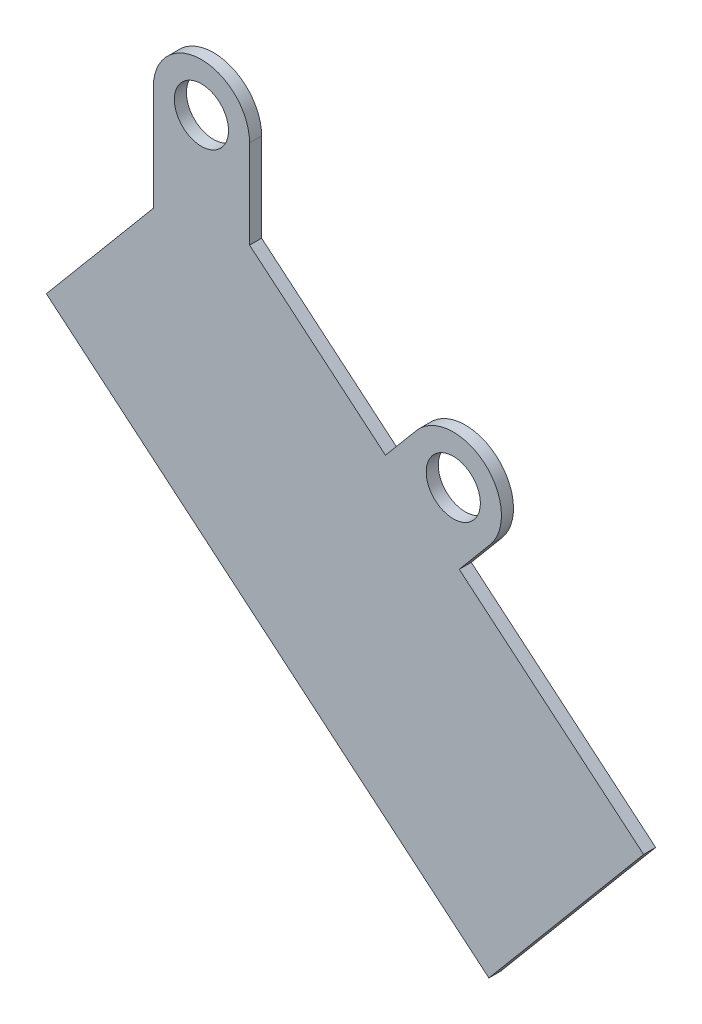
from build123d import *

# Parameters (mm, degrees)
SKETCH1_R           = 14.2875
BOSS_EXTRUDE1_DEPTH = 3.175


with BuildPart() as part:
    # Sketch1 → Boss-Extrude1 (new body, symmetric)
    with BuildSketch(Plane.XY):
        with BuildLine():
            Line((-56.421183023, 233.069398752), (177.06916324, 37.147735319))
            Line((177.06916324, 37.147735319), (258.70318967, 134.435379595))
            Line((258.70318967, 134.435379595), (161.415545394, 216.069406025))
            Line((161.415545394, 216.069406025), (177.74235068, 235.526934881))
            ThreePointArc((177.74235068, 235.526934881), (174.611627111, 271.311269022), (138.82729297, 268.180545453))
            Line((138.82729297, 268.180545453), (122.500487684, 248.723016597))
            Line((122.500487684, 248.723016597), (50.8, 308.886869368))
            Line((50.8, 308.886869368), (50.8, 355.6))
            ThreePointArc((50.8, 355.6), (25.4, 381), (0, 355.6))
            Line((0, 355.6), (0, 300.309546317))
            Line((0, 300.309546317), (-56.421183023, 233.069398752))
        make_face()
        with Locations((25.4, 355.6)):
            Circle(SKETCH1_R, mode=Mode.SUBTRACT)
        with Locations((158.284821825, 251.853740167)):
            Circle(SKETCH1_R, mode=Mode.SUBTRACT)
    extrude(amount=BOSS_EXTRUDE1_DEPTH, both=True)


solid = part.part
